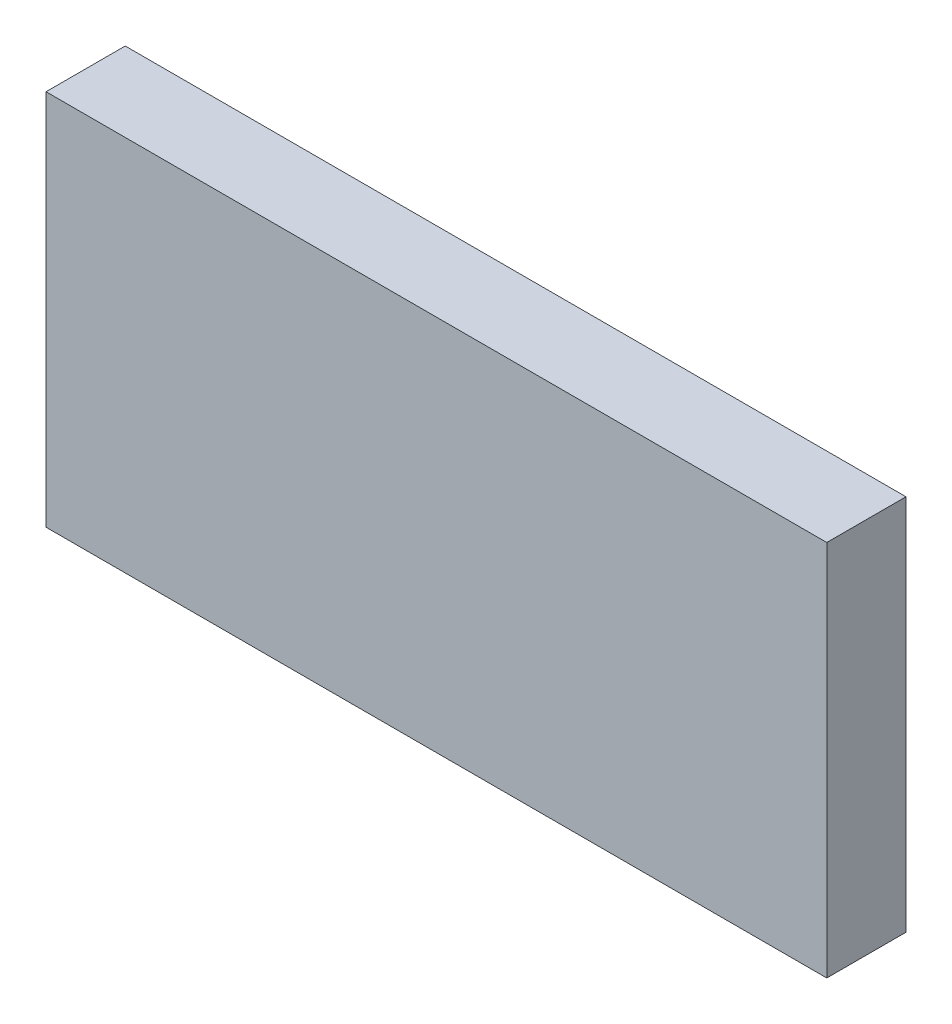
from build123d import *

# Parameters (mm, degrees)
SKETCH1_W           = 52.578
SKETCH1_H           = 25.4
BOSS_EXTRUDE1_DEPTH = 5.334


with BuildPart() as part:
    # Sketch1 → Boss-Extrude1 (new body)
    with BuildSketch(Plane.XY):
        Rectangle(SKETCH1_W, SKETCH1_H)
    extrude(amount=BOSS_EXTRUDE1_DEPTH)


solid = part.part
